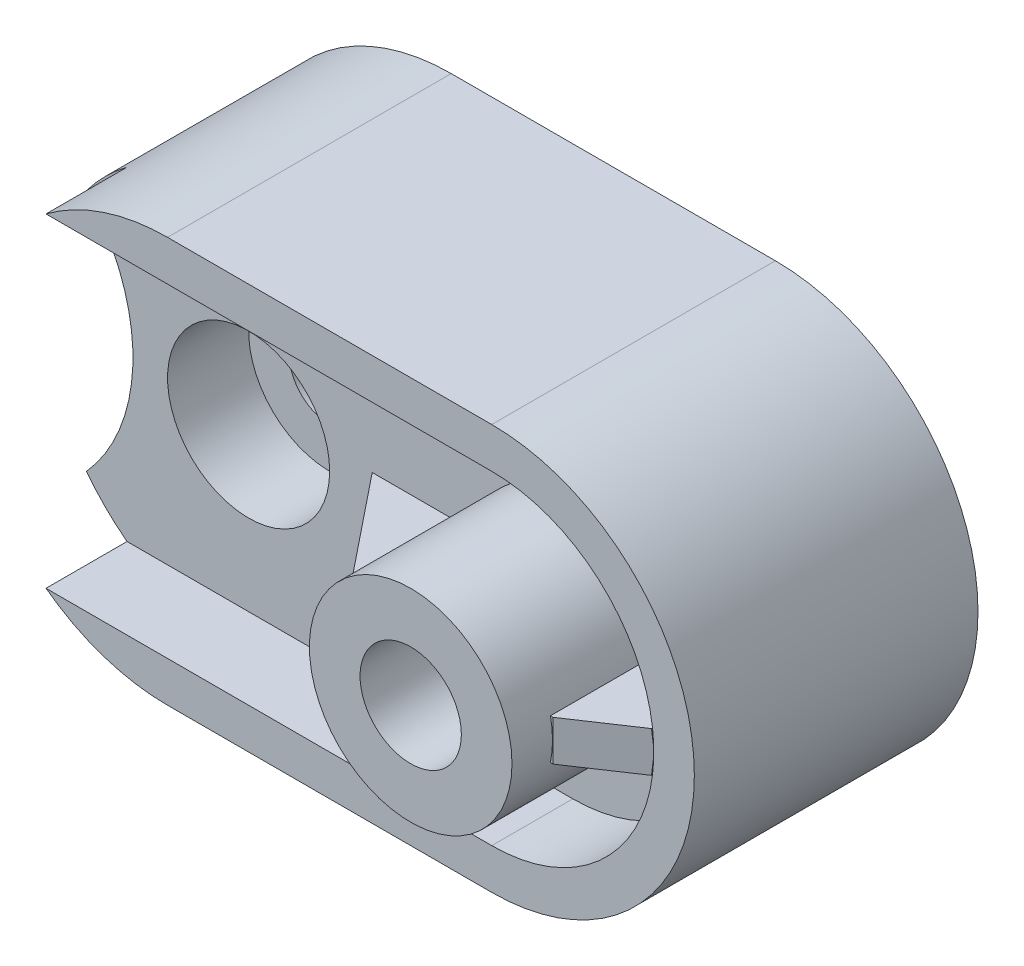
from build123d import *

# Parameters (mm, degrees)
SKETCH1_W                  = 180
SKETCH1_H                  = 100
BOSS_EXTRUDE2_DEPTH        = 70
CUT_EXTRUDE1_DEPTH         = 70
SKETCH3_R                  = 5
CUT_EXTRUDE2_DEPTH         = 70
SKETCH4_R                  = 5
CUT_EXTRUDE3_DEPTH         = 50
SKETCH5_R                  = 10
CUT_EXTRUDE4_DEPTH         = 106
SKETCH6_R                  = 15
CUT_EXTRUDE5_DEPTH         = 40
SKETCH8_R                  = 15
SKETCH8_R_2                = 12.5
BOSS_EXTRUDE3_DEPTH        = 40
SKETCH10_R                 = 12.5
BOSS_EXTRUDE4_DEPTH        = 65
F_25_0MM_DOWEL_HOLE2_D     = 25
F_25_0MM_DOWEL_HOLE2_DEPTH = 20
F_25_0MM_DOWEL_HOLE2_TIP   = 7.510757738
SKETCH12_R                 = 10
SKETCH12_R_2               = 12.5
CUT_EXTRUDE6_DEPTH         = 20
SKETCH13_R                 = 25
SKETCH13_R_2               = 12.5
BOSS_EXTRUDE5_DEPTH        = 40
SKETCH14_R                 = 20
SKETCH14_R_2               = 10
CUT_EXTRUDE7_DEPTH         = 20
BOSS_EXTRUDE10_DEPTH       = 30
BOSS_EXTRUDE13_DEPTH       = 30
CUT_EXTRUDE8_DEPTH         = 5


with BuildPart() as part:
    # Sketch1 → Boss-Extrude2 (new body)
    with BuildSketch(Plane.XY):
        with Locations((90, 50)):
            Rectangle(SKETCH1_W, SKETCH1_H)
    extrude(amount=BOSS_EXTRUDE2_DEPTH)

    # Sketch2 → Cut-Extrude1 (cut)
    with BuildSketch(Plane.XY.offset(70)):
        with BuildLine():
            Line((50, 100), (0, 100))
            Line((0, 100), (0, 50))
            ThreePointArc((0, 50), (14.644660941, 85.355339059), (50, 100))
        make_face()
        with BuildLine():
            ThreePointArc((50, 0), (14.644660941, 14.644660941), (0, 50))
            Line((0, 50), (0, 0))
            Line((0, 0), (50, 0))
        make_face()
        with BuildLine():
            Line((180, 0), (180, 50))
            ThreePointArc((180, 50), (165.355339059, 14.644660941), (130, 0))
            Line((130, 0), (180, 0))
        make_face()
        with BuildLine():
            Line((180, 100), (130, 100))
            ThreePointArc((130, 100), (165.355339059, 85.355339059), (180, 50))
            Line((180, 50), (180, 100))
        make_face()
    extrude(amount=-CUT_EXTRUDE1_DEPTH, mode=Mode.SUBTRACT)

    # Sketch3 → Cut-Extrude2 (cut)
    with BuildSketch(Plane.XY.offset(70)):
        with Locations((10, 50)):
            Circle(SKETCH3_R)
    extrude(amount=-CUT_EXTRUDE2_DEPTH, mode=Mode.SUBTRACT)

    # Sketch4 → Cut-Extrude3 (cut)
    with BuildSketch(Plane.XY.offset(70)):
        with BuildLine():
            ThreePointArc((10, 20), (21.458980338, 50), (10, 80))
            ThreePointArc((10, 80), (0, 50), (10, 20))
        make_face()
        with Locations((10, 50)):
            Circle(SKETCH4_R, mode=Mode.SUBTRACT)
    extrude(amount=-CUT_EXTRUDE3_DEPTH, mode=Mode.SUBTRACT)

    # Sketch5 → Cut-Extrude4 (cut)
    with BuildSketch(Plane.XY.offset(70)):
        with Locations((50, 50)):
            Circle(SKETCH5_R)
    extrude(amount=-CUT_EXTRUDE4_DEPTH, mode=Mode.SUBTRACT)

    # Sketch6 → Cut-Extrude5 (cut)
    with BuildSketch(Plane.XY.offset(70)):
        with Locations((130, 50)):
            Circle(SKETCH6_R)
    extrude(amount=-CUT_EXTRUDE5_DEPTH, mode=Mode.SUBTRACT)

    # Sketch8 → Boss-Extrude3 (add)
    with BuildSketch(Plane.XY.offset(70)):
        with Locations((130, 50)):
            Circle(SKETCH8_R)
        with Locations((130, 50)):
            Circle(SKETCH8_R_2, mode=Mode.SUBTRACT)
    extrude(amount=-BOSS_EXTRUDE3_DEPTH)

    # Sketch10 → Boss-Extrude4 (add)
    with BuildSketch(Plane.XY.offset(70)):
        with Locations((130, 50)):
            Circle(SKETCH10_R)
    extrude(amount=-BOSS_EXTRUDE4_DEPTH)

    # Ø25.0mm Dowel Hole2
    with Locations(Plane(origin=(130, 50, 70), x_dir=(1, 0, 0), z_dir=(0, 0, 1))):
        with Locations((0, 0)):
            Hole(F_25_0MM_DOWEL_HOLE2_D / 2, depth=F_25_0MM_DOWEL_HOLE2_DEPTH)
            with Locations((0, 0, -(F_25_0MM_DOWEL_HOLE2_DEPTH + F_25_0MM_DOWEL_HOLE2_TIP / 2))):  # 118° drill point
                Cone(0, F_25_0MM_DOWEL_HOLE2_D / 2, F_25_0MM_DOWEL_HOLE2_TIP, mode=Mode.SUBTRACT)

    # Sketch12 → Cut-Extrude6 (cut)
    with BuildSketch(Plane.XY.offset(70)):
        with BuildLine():
            ThreePointArc((130, 10), (170, 50), (130, 90))
            Line((130, 90), (20, 90))
            ThreePointArc((20, 90), (14.644660941, 85.355339059), (10, 80))
            ThreePointArc((10, 80), (21.458980338, 50), (10, 20))
            ThreePointArc((10, 20), (14.644660941, 14.644660941), (20, 10))
            Line((20, 10), (130, 10))
        make_face()
        with Locations((50, 50)):
            Circle(SKETCH12_R, mode=Mode.SUBTRACT)
        with Locations((130, 50)):
            Circle(SKETCH12_R_2, mode=Mode.SUBTRACT)
    extrude(amount=-CUT_EXTRUDE6_DEPTH, mode=Mode.SUBTRACT)

    # Sketch13 → Boss-Extrude5 (add)
    with BuildSketch(Plane.XY.offset(50)):
        with Locations((130, 50)):
            Circle(SKETCH13_R)
        with Locations((130, 50)):
            Circle(SKETCH13_R_2, mode=Mode.SUBTRACT)
    extrude(amount=BOSS_EXTRUDE5_DEPTH)

    # Sketch14 → Cut-Extrude7 (cut)
    with BuildSketch(Plane.XY.offset(50)):
        with Locations((50, 50)):
            Circle(SKETCH14_R)
        with Locations((50, 50)):
            Circle(SKETCH14_R_2, mode=Mode.SUBTRACT)
    extrude(amount=-CUT_EXTRUDE7_DEPTH, mode=Mode.SUBTRACT)

    # Sketch15 → Boss-Extrude10 (add)
    with BuildSketch(Plane.XY.offset(50)):
        with BuildLine():
            Line((105.505102572, 45), (105.505102572, 55))
            ThreePointArc((105.505102572, 55), (105, 50), (105.505102572, 45))
        make_face()
        with BuildLine():
            ThreePointArc((105.505102572, 45), (105, 50), (105.505102572, 55))
            Line((105.505102572, 55), (80.505102572, 55))
            Line((80.505102572, 55), (80.505102572, 45))
            Line((80.505102572, 45), (105.505102572, 45))
        make_face()
    extrude(amount=BOSS_EXTRUDE10_DEPTH)

    # Sketch16 → Boss-Extrude13 (add)
    with BuildSketch(Plane.XY.offset(50)):
        with BuildLine():
            Line((169.686269666, 55), (154.494897428, 55))
            ThreePointArc((154.494897428, 55), (155, 50), (154.494897428, 45))
            Line((154.494897428, 45), (169.686269666, 45))
            ThreePointArc((169.686269666, 45), (169.921490369, 47.495083498), (170, 50))
            ThreePointArc((170, 50), (169.921490369, 52.504916502), (169.686269666, 55))
        make_face()
    extrude(amount=BOSS_EXTRUDE13_DEPTH)

    # Sketch18 → Cut-Extrude8 (cut, symmetric)
    with BuildSketch(Plane(origin=(0, 50, 0), x_dir=(1, 0, 0), z_dir=(0, 1, 0))):
        Polygon((155.156999003, -80), (170.098617307, -70), (170.098617307, -80), align=None)
        Polygon((104.578940911, -80), (80.505102572, -50), (80.505102572, -80), align=None)
    extrude(amount=CUT_EXTRUDE8_DEPTH, both=True, mode=Mode.SUBTRACT)


solid = part.part
